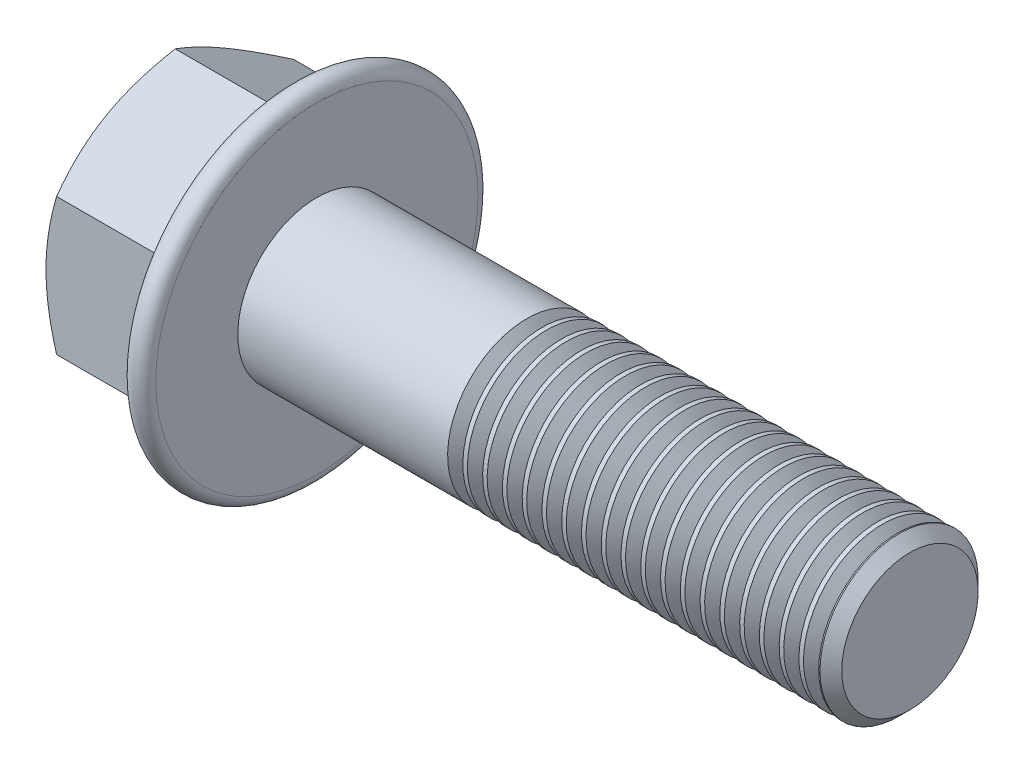
from build123d import *

# Parameters (mm, degrees)
BASEHEAD_DEPTH    = 15.4
FLANGEHEXFILLET_R = 1
THDSCHPAT_COUNT   = 19
THDSCHPAT_PITCH   = 2


with BuildPart() as part:
    # Sketch1 → BaseHead (new body)
    with BuildSketch(Plane(origin=(0, 0, 0), x_dir=(0, 0, -1), z_dir=(1, 0, 0))):
        Polygon((12, 6.92820323), (12, -6.92820323), (0, -13.856406461), (-12, -6.92820323), (-12, 6.92820323), (0, 13.856406461), align=None)
    extrude(amount=BASEHEAD_DEPTH)

    # BodySke → BaseBody (revolve)
    with BuildSketch(Plane.XY, mode=Mode.PRIVATE) as basebody_sk:
        Polygon((0, 0), (75.4, 0), (75.4, 6.8985), (74.2985, 8), (0, 8), align=None)
    revolve(basebody_sk.sketch.rotate(Axis((0, 0, 0), (1, 0, 0)), 90), axis=Axis((0, 0, 0), (1, 0, 0)))

    # Sketch3 → HeadChamfer (revolve, cut)
    with BuildSketch(Plane.XY, mode=Mode.PRIVATE) as headchamfer_sk:
        Polygon((0, 12), (3.958548116, 18.856406461), (3.958548116, 23.856406461), (-10, 23.856406461), (-10, 12), align=None)
    revolve(headchamfer_sk.sketch.rotate(Axis((0, 0, 0), (1, 0, 0)), 90), axis=Axis((0, 0, 0), (1, 0, 0)), mode=Mode.SUBTRACT)

    # Sketch4 → Flange (revolve)
    with BuildSketch(Plane.XY, mode=Mode.PRIVATE) as flange_sk:
        with BuildLine():
            Line((6.990271854, 0), (13.072368855, 16.710424172))
            ThreePointArc((13.072368855, 16.710424172), (14.408377813, 17.481769304), (15.4, 16.3))
            Line((15.4, 16.3), (15.4, 0))
            Line((15.4, 0), (6.990271854, 0))
        make_face()
    revolve(flange_sk.sketch.rotate(Axis((0, 0, 0), (1, 0, 0)), 90), axis=Axis((0, 0, 0), (1, 0, 0)))

    # FlangeHexFillet
    flangehexfillet_edges = [part.edges().sort_by_distance(p)[0] for p in [
        (11.357914666, 0, -12),
        (11.357914666, -10.392304845, -6),
        (11.537787161, 3.479213152, 12),
        (11.357914666, 10.392304845, 6),
        (11.357914666, 10.392304845, -6),
        (11.357914666, -10.392304845, 6),
        (11.537787161, -3.479213152, 12),
    ]]
    fillet(flangehexfillet_edges, radius=FLANGEHEXFILLET_R)

    # ThdSchSke → ThreadSchematic (revolve, cut)
    with BuildSketch(Plane.XY):
        Polygon((37.4, -6.8985), (36.628721397, -8), (36.628721397, -10), (38.171278603, -10), (38.171278603, -8), align=None)
    threadschematic = revolve(axis=Axis((-3.175, 0, 0), (1, 0, 0)), mode=Mode.SUBTRACT)

    # ThdSchPat: ThreadSchematic ×19
    with Locations(*[(i * THDSCHPAT_PITCH, 0, 0) for i in range(1, THDSCHPAT_COUNT)]):
        add(threadschematic, mode=Mode.SUBTRACT)


solid = part.part
